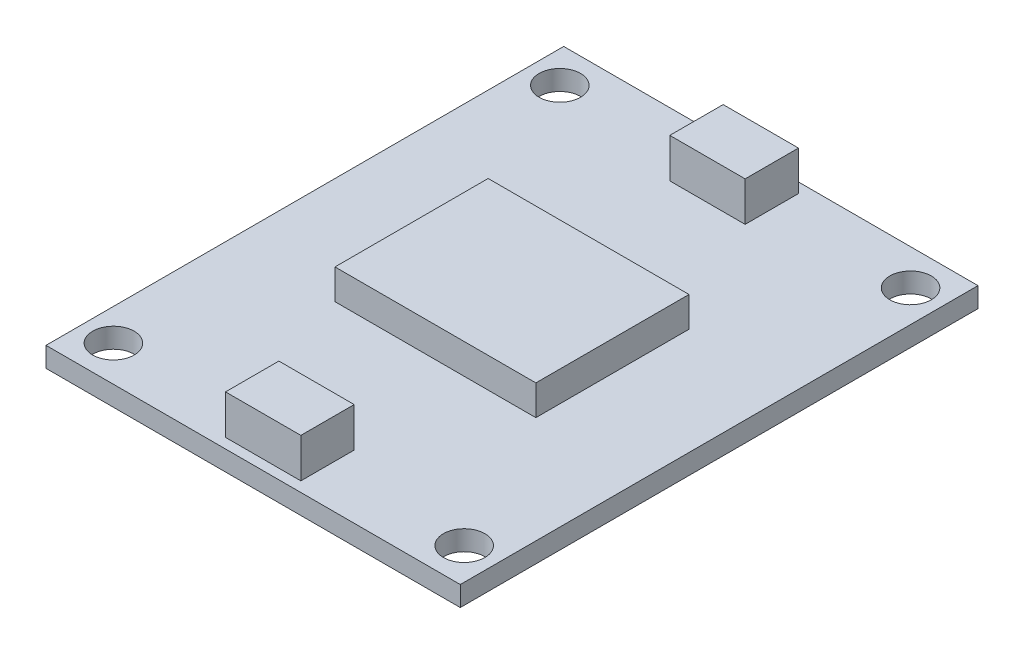
from build123d import *

# Parameters (mm, degrees)
SKETCH1_W            = 33
SKETCH1_H            = 41.24
BOSS_EXTRUDE1_DEPTH  = 1.59
M3_CLEARANCE_HOLE1_D = 3.3
SKETCH6_W            = 16
SKETCH6_H            = 12.2
M8P_DEPTH            = 2.4
SKETCH7_W            = 6
SKETCH7_H            = 4.25
I2C_CONNECTORS_DEPTH = 3.14


with BuildPart() as part:
    # Sketch1 → Boss-Extrude1 (new body)
    with BuildSketch(Plane(origin=(0, 0, 0), x_dir=(1, 0, 0), z_dir=(0, 1, 0))):
        Rectangle(SKETCH1_W, SKETCH1_H)
    extrude(amount=BOSS_EXTRUDE1_DEPTH)

    # M3 Clearance Hole1 (through all)
    with Locations(Plane(origin=(0, 1.59, 0), x_dir=(1, 0, 0), z_dir=(0, 1, 0))):
        with Locations((-13.97, 17.78), (13.97, 17.78), (13.97, -17.78), (-13.97, -17.78)):
            Hole(M3_CLEARANCE_HOLE1_D / 2)

    # Sketch6 → M8P (add)
    with BuildSketch(Plane(origin=(0, 1.59, 0), x_dir=(1, 0, 0), z_dir=(0, 1, 0))):
        Rectangle(SKETCH6_W, SKETCH6_H)
    extrude(amount=M8P_DEPTH)

    # Sketch7 → I2C connectors (add)
    with BuildSketch(Plane(origin=(0, 1.59, 0), x_dir=(1, 0, 0), z_dir=(0, 1, 0))):
        with Locations((0, -17.695)):
            Rectangle(SKETCH7_W, SKETCH7_H)
        with Locations((0, 17.695)):
            Rectangle(SKETCH7_W, SKETCH7_H)
    extrude(amount=I2C_CONNECTORS_DEPTH)


solid = part.part
